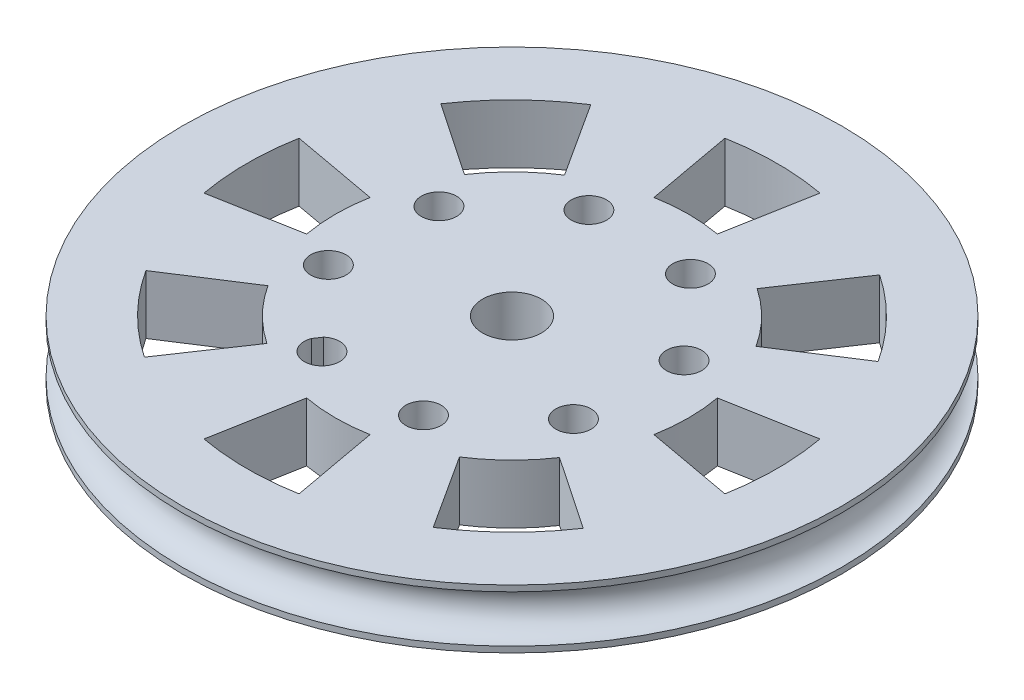
from build123d import *

# Parameters (mm, degrees)
SKETCH6_R                = 28
BOSS_EXTRUDE3_DEPTH      = 5
CUT_EXTRUDE4_DEPTH       = 40.912404087
CUT_EXTRUDE4_DEPTH_BACK  = 40.912404087
CUT_EXTRUDE5_DEPTH       = 40.912404087
CUT_EXTRUDE5_DEPTH_BACK  = 40.912404087
SKETCH7_8_R              = 1.5
SKETCH10_R               = 2
CUT_EXTRUDE14_DEPTH      = 40.912404087
CUT_EXTRUDE14_DEPTH_BACK = 5
SKETCH11_R               = 2.5
SKETCH12_R               = 9
BOSS_EXTRUDE4_DEPTH      = 4


with BuildPart() as part:
    # Sketch6 → Boss-Extrude3 (new body)
    with BuildSketch(Plane(origin=(0, 0, 0), x_dir=(1, 0, 0), z_dir=(0, 1, 0))):
        Circle(SKETCH6_R)
    extrude(amount=BOSS_EXTRUDE3_DEPTH)

    # Sketch7 → Cut-Extrude4 (cut, two sides: drawn at the far end of the back side and taken through both)
    with BuildSketch(Plane(origin=(0, 5, 0), x_dir=(1, 0, 0), z_dir=(0, 1, 0)).offset(-CUT_EXTRUDE4_DEPTH_BACK)):
        with BuildLine():
            ThreePointArc((22.134158375, -4.040919826), (22.5, 0), (22.134158375, 4.040919826))
            Line((22.134158375, 4.040919826), (14.756105583, 2.693946551))
            ThreePointArc((14.756105583, 2.693946551), (15, 0), (14.756105583, -2.693946551))
            Line((14.756105583, -2.693946551), (22.134158375, -4.040919826))
        make_face()
        with BuildLine():
            Line((12.600595793, 8.137873534), (18.900893689, 12.206810302))
            ThreePointArc((18.900893689, 12.206810302), (16.072652831, 15.745470173), (12.592900123, 18.645880684))
            Line((12.592900123, 18.645880684), (8.395266749, 12.430587123))
            ThreePointArc((8.395266749, 12.430587123), (10.715101887, 10.496980115), (12.600595793, 8.137873534))
        make_face()
        with BuildLine():
            ThreePointArc((12.206810302, -18.900893689), (15.745470173, -16.072652831), (18.645880684, -12.592900123))
            Line((18.645880684, -12.592900123), (12.430587123, -8.395266749))
            ThreePointArc((12.430587123, -8.395266749), (10.496980115, -10.715101887), (8.137873534, -12.600595793))
            Line((8.137873534, -12.600595793), (12.206810302, -18.900893689))
        make_face()
        with BuildLine():
            Line((2.693946551, 14.756105583), (4.040919826, 22.134158375))
            ThreePointArc((4.040919826, 22.134158375), (0, 22.5), (-4.040919826, 22.134158375))
            Line((-4.040919826, 22.134158375), (-2.693946551, 14.756105583))
            ThreePointArc((-2.693946551, 14.756105583), (0, 15), (2.693946551, 14.756105583))
        make_face()
        with BuildLine():
            ThreePointArc((-4.040919826, -22.134158375), (0, -22.5), (4.040919826, -22.134158375))
            Line((4.040919826, -22.134158375), (2.693946551, -14.756105583))
            ThreePointArc((2.693946551, -14.756105583), (0, -15), (-2.693946551, -14.756105583))
            Line((-2.693946551, -14.756105583), (-4.040919826, -22.134158375))
        make_face()
        with BuildLine():
            Line((-8.137873534, 12.600595793), (-12.206810302, 18.900893689))
            ThreePointArc((-12.206810302, 18.900893689), (-15.745470173, 16.072652831), (-18.645880684, 12.592900123))
            Line((-18.645880684, 12.592900123), (-12.430587123, 8.395266749))
            ThreePointArc((-12.430587123, 8.395266749), (-10.496980115, 10.715101887), (-8.137873534, 12.600595793))
        make_face()
        with BuildLine():
            ThreePointArc((-18.900893689, -12.206810302), (-16.072652831, -15.745470173), (-12.592900123, -18.645880684))
            Line((-12.592900123, -18.645880684), (-8.395266749, -12.430587123))
            ThreePointArc((-8.395266749, -12.430587123), (-10.715101887, -10.496980115), (-12.600595793, -8.137873534))
            Line((-12.600595793, -8.137873534), (-18.900893689, -12.206810302))
        make_face()
        with BuildLine():
            Line((-14.756105583, 2.693946551), (-22.134158375, 4.040919826))
            ThreePointArc((-22.134158375, 4.040919826), (-22.5, 0), (-22.134158375, -4.040919826))
            Line((-22.134158375, -4.040919826), (-14.756105583, -2.693946551))
            ThreePointArc((-14.756105583, -2.693946551), (-15, 0), (-14.756105583, 2.693946551))
        make_face()
    extrude(amount=CUT_EXTRUDE4_DEPTH + CUT_EXTRUDE4_DEPTH_BACK, mode=Mode.SUBTRACT)

    # Sketch7_8 → Cut-Extrude5 (cut, two sides: drawn at the far end of the back side and taken through both)
    with BuildSketch(Plane(origin=(0, 5, 0), x_dir=(1, 0, 0), z_dir=(0, 1, 0)).offset(-CUT_EXTRUDE5_DEPTH_BACK)):
        with Locations((10.5755737, 4.040919826)):
            Circle(SKETCH7_8_R)
        with Locations((10.190896389, -4.969613007)):
            Circle(SKETCH7_8_R)
        with Locations((4.476172766, 10.68433663)):
            Circle(SKETCH7_8_R)
        with Locations((3.547479586, -11.06901394)):
            Circle(SKETCH7_8_R)
        with Locations((-4.534360067, 11.06901394)):
            Circle(SKETCH7_8_R)
        with BuildLine():
            ThreePointArc((-6.876220335, -10.181386548), (-4.219994535, -11.523863304), (-6.457430859, -9.561299157))
            Line((-6.457430859, -9.561299157), (-6.876220335, -10.181386548))
        make_face()
        with Locations((-11.17777687, 4.969613007)):
            Circle(SKETCH7_8_R)
        with Locations((-11.562454181, -4.040919826)):
            Circle(SKETCH7_8_R)
    extrude(amount=CUT_EXTRUDE5_DEPTH + CUT_EXTRUDE5_DEPTH_BACK, mode=Mode.SUBTRACT)

    # Sketch10 → Cut-Revolve1 (revolve, cut)
    with BuildSketch(Plane.XY):
        with Locations((28, 2.5)):
            Circle(SKETCH10_R)
    revolve(axis=Axis((0, 40.614262211, 0), (0, -1, 0)), mode=Mode.SUBTRACT)

    # Sketch11 → Cut-Extrude14 (cut, two sides: drawn at the far end of the back side and taken through both)
    with BuildSketch(Plane(origin=(0, 0, 0), x_dir=(1, 0, 0), z_dir=(0, 1, 0)).offset(-CUT_EXTRUDE14_DEPTH_BACK)):
        Circle(SKETCH11_R)
    extrude(amount=CUT_EXTRUDE14_DEPTH + CUT_EXTRUDE14_DEPTH_BACK, mode=Mode.SUBTRACT)

    # Sketch12 → Boss-Extrude4 (add)
    with BuildSketch(Plane(origin=(0, 0, 0), x_dir=(1, 0, 0), z_dir=(0, 1, 0))):
        Circle(SKETCH12_R)
        Polygon((0, 7), (-6.062177826, 3.5), (-6.062177826, -3.5), (0, -7), (6.062177826, -3.5), (6.062177826, 3.5), align=None, mode=Mode.SUBTRACT)
    extrude(amount=-BOSS_EXTRUDE4_DEPTH)


solid = part.part
